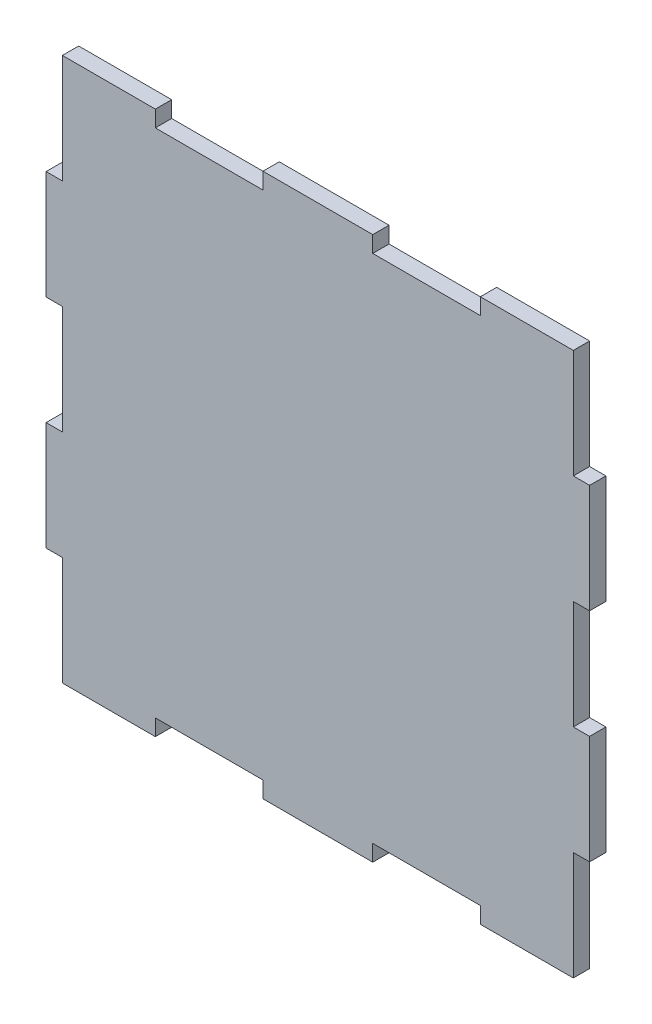
from build123d import *

# Parameters (mm, degrees)
BOSS_EXTRUDE1_DEPTH = 3


with BuildPart() as part:
    # Sketch1 → Boss-Extrude1 (new body)
    with BuildSketch(Plane.XY):
        Polygon((60.1, 97), (60.1, 100), (39.9, 100), (39.9, 97), (20.1, 97), (20.1, 100), (3, 100), (3, 80), (0, 80), (0, 60), (3, 60), (3, 40), (0, 40), (0, 20), (3, 20), (3, 0), (20.1, 0), (20.1, 3), (39.9, 3), (39.9, 0), (60.1, 0), (60.1, 3), (79.9, 3), (79.9, 0), (97, 0), (97, 20), (100, 20), (100, 40), (97, 40), (97, 60), (100, 60), (100, 80), (97, 80), (97, 100), (79.9, 100), (79.9, 97), align=None)
    extrude(amount=BOSS_EXTRUDE1_DEPTH)


solid = part.part
